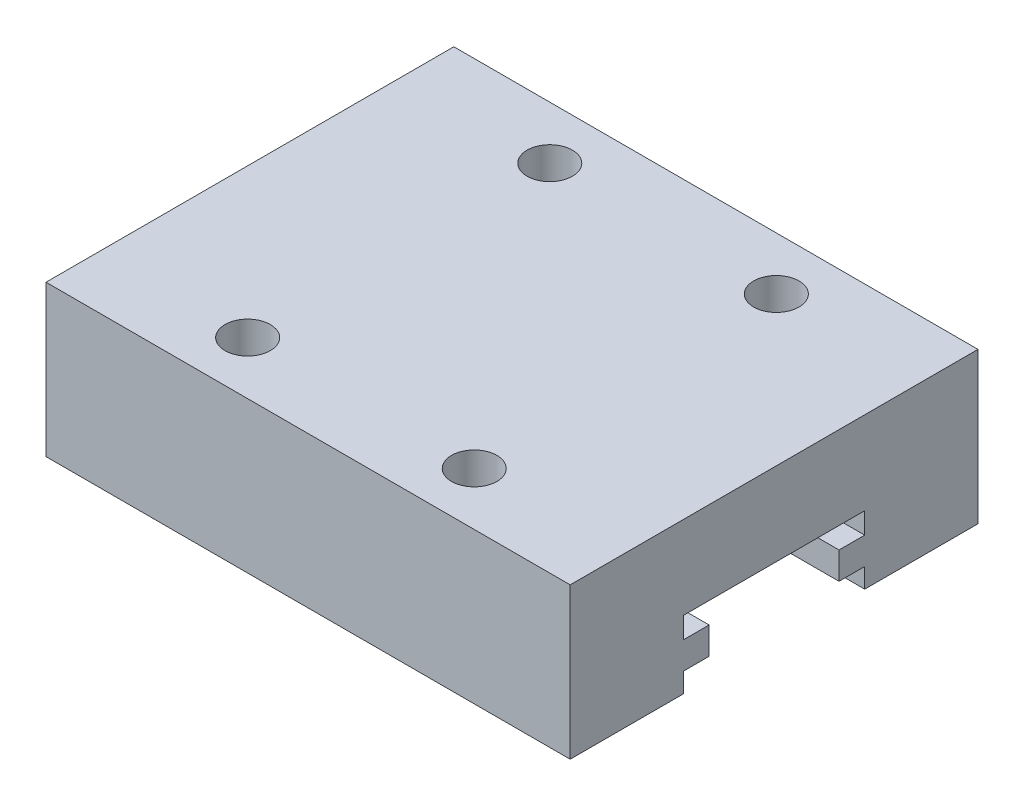
from build123d import *

# Parameters (mm, degrees)
CROQUIS1_W              = 34.7
CROQUIS1_H              = 27
SALIENTE_EXTRUIR1_DEPTH = 10
CROQUIS2_R              = 1.5
CORTAR_EXTRUIR1_DEPTH   = 5
CORTAR_EXTRUIR2_DEPTH   = 34.7


with BuildPart() as part:
    # Croquis1 → Saliente-Extruir1 (new body)
    with BuildSketch(Plane(origin=(0, 0, 0), x_dir=(1, 0, 0), z_dir=(0, 1, 0))):
        with Locations((17.35, 13.5)):
            Rectangle(CROQUIS1_W, CROQUIS1_H)
    extrude(amount=SALIENTE_EXTRUIR1_DEPTH)

    # Croquis2 → Cortar-Extruir1 (cut)
    with BuildSketch(Plane(origin=(0, 10, 0), x_dir=(1, 0, 0), z_dir=(0, 1, 0))):
        with Locations((9.85, 23.5)):
            Circle(CROQUIS2_R)
        with Locations((24.849986467, 23.5)):
            Circle(CROQUIS2_R)
        with Locations((9.85, 3.5)):
            Circle(CROQUIS2_R)
        with Locations((24.849986467, 3.5)):
            Circle(CROQUIS2_R)
    extrude(amount=-CORTAR_EXTRUIR1_DEPTH, mode=Mode.SUBTRACT)

    # Croquis3 → Cortar-Extruir2 (cut)
    with BuildSketch(Plane(origin=(34.7, 0, 0), x_dir=(0, 0, -1), z_dir=(1, 0, 0))):
        Polygon((7.5, 0), (19.5, 0), (19.5, 1.3), (17.8, 1.3), (17.8, 3.1), (19.5, 3.1), (19.5, 4.5), (7.5, 4.5), (7.5, 3.1), (9.2, 3.1), (9.2, 1.3), (7.5, 1.3), align=None)
    extrude(amount=-CORTAR_EXTRUIR2_DEPTH, mode=Mode.SUBTRACT)


solid = part.part
